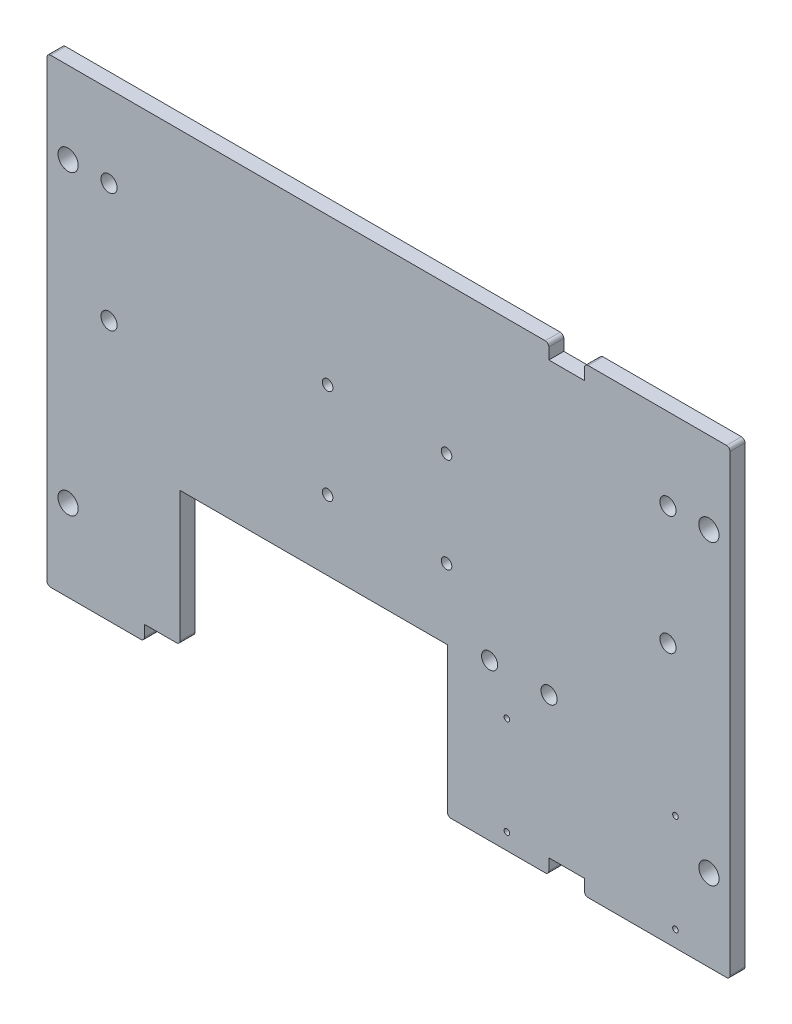
from build123d import *

# Parameters (mm, degrees)
SKETCH1_W           = 145.885353282
SKETCH1_H           = 98.425
BOSS_EXTRUDE1_DEPTH = 3.2004
SKETCH4_W           = 57.100000132
SKETCH4_H           = 31.75
CUT_EXTRUDE1_DEPTH  = 3.2004
SKETCH5_R           = 2.159
CUT_EXTRUDE2_DEPTH  = 3.2004
SKETCH7_R           = 1.1303
CUT_EXTRUDE3_DEPTH  = 3.2004
SKETCH9_W           = 7.62
SKETCH9_H           = 3.175
CUT_EXTRUDE5_DEPTH  = 3.2004
SKETCH10_R          = 0.59563
CUT_EXTRUDE6_DEPTH  = 3.2004
FILLET1_R           = 0.762
SKETCH11_R          = 1.7272
CUT_EXTRUDE7_DEPTH  = 3.2004


with BuildPart() as part:
    # Sketch1 → Boss-Extrude1 (new body)
    with BuildSketch(Plane.XY):
        with Locations((72.942676641, 49.2125)):
            Rectangle(SKETCH1_W, SKETCH1_H)
    extrude(amount=BOSS_EXTRUDE1_DEPTH)

    # Sketch4 → Cut-Extrude1 (cut)
    with BuildSketch(Plane.XY.offset(3.2004)):
        with Locations((56.982760066, 15.875)):
            Rectangle(SKETCH4_W, SKETCH4_H)
    extrude(amount=-CUT_EXTRUDE1_DEPTH, mode=Mode.SUBTRACT)

    # Sketch5 → Cut-Extrude2 (cut)
    with BuildSketch(Plane.XY.offset(3.2004)):
        with Locations((141.376853282, 80.9625)):
            Circle(SKETCH5_R)
        with Locations((141.376853282, 17.4625)):
            Circle(SKETCH5_R)
        with Locations((4.5085, 17.4625)):
            Circle(SKETCH5_R)
        with Locations((4.5085, 80.9625)):
            Circle(SKETCH5_R)
    extrude(amount=-CUT_EXTRUDE2_DEPTH, mode=Mode.SUBTRACT)

    # Sketch7 → Cut-Extrude3 (cut)
    with BuildSketch(Plane(origin=(0, 0, 0), x_dir=(-1, 0, 0), z_dir=(0, 0, -1))):
        with Locations((-59.937161658, 67.017728802)):
            Circle(SKETCH7_R)
        with Locations((-59.937161658, 46.697728802)):
            Circle(SKETCH7_R)
        with Locations((-85.337161658, 46.697728802)):
            Circle(SKETCH7_R)
        with Locations((-85.337161658, 67.017728802)):
            Circle(SKETCH7_R)
    extrude(amount=-CUT_EXTRUDE3_DEPTH, mode=Mode.SUBTRACT)

    # Sketch9 → Cut-Extrude5 (cut)
    with BuildSketch(Plane.XY.offset(3.2004)):
        with Locations((110.993373282, 96.8375)):
            Rectangle(SKETCH9_W, SKETCH9_H)
        with Locations((110.993373282, 1.5875)):
            Rectangle(SKETCH9_W, SKETCH9_H)
        with Locations((24.62276, 1.5875)):
            Rectangle(SKETCH9_W, SKETCH9_H)
    extrude(amount=-CUT_EXTRUDE5_DEPTH, mode=Mode.SUBTRACT)

    # Sketch10 → Cut-Extrude6 (cut)
    with BuildSketch(Plane.XY.offset(3.2004)):
        with Locations((98.232760132, 24.47)):
            Circle(SKETCH10_R)
        with Locations((134.232760132, 24.47)):
            Circle(SKETCH10_R)
        with Locations((98.232760132, 3.47)):
            Circle(SKETCH10_R)
        with Locations((134.232760132, 3.47)):
            Circle(SKETCH10_R)
    extrude(amount=-CUT_EXTRUDE6_DEPTH, mode=Mode.SUBTRACT)

    # Fillet1
    fillet1_edges = [part.edges().sort_by_distance(p)[0] for p in [
        (85.532760132, 0, 1.6002),
        (0, 98.425, 1.6002),
        (145.885353282, 98.425, 1.6002),
        (145.885353282, 0, 1.6002),
        (0, 0, 1.6002),
        (114.803373282, 98.425, 1.6002),
        (107.183373282, 98.425, 1.6002),
        (114.803373282, 0, 1.6002),
        (107.183373282, 0, 1.6002),
        (28.43276, 3.175, 1.6002),
        (20.81276, 0, 1.6002),
    ]]
    fillet(fillet1_edges, radius=FILLET1_R)

    # Sketch11 → Cut-Extrude7 (cut)
    with BuildSketch(Plane.XY.offset(3.2004)):
        with Locations((13.252676641, 55.5625)):
            Circle(SKETCH11_R)
        with Locations((13.252676641, 80.9625)):
            Circle(SKETCH11_R)
        with Locations((132.632676641, 55.5625)):
            Circle(SKETCH11_R)
        with Locations((132.632676641, 80.9625)):
            Circle(SKETCH11_R)
        with Locations((107.232676641, 33.3375)):
            Circle(SKETCH11_R)
        with Locations((94.532676641, 33.3375)):
            Circle(SKETCH11_R)
    extrude(amount=-CUT_EXTRUDE7_DEPTH, mode=Mode.SUBTRACT)


solid = part.part
